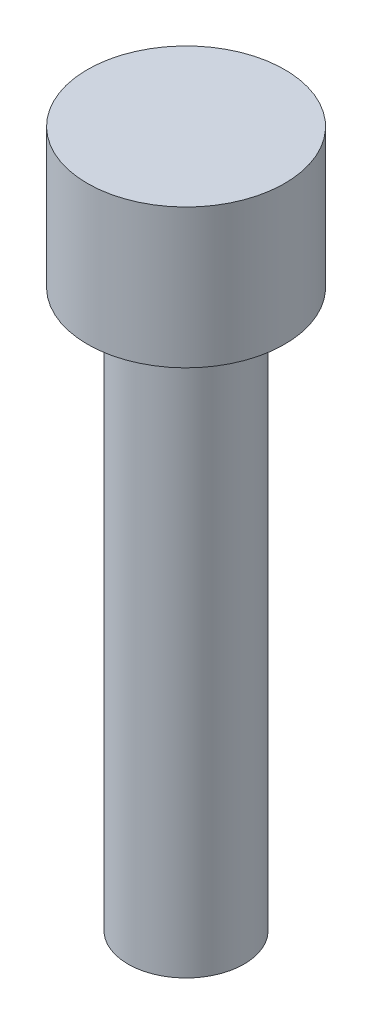
from build123d import *

# Parameters (mm, degrees)
SKETCH1_R           = 2.5
BOSS_EXTRUDE1_DEPTH = 24
SKETCH2_R           = 4.25
BOSS_EXTRUDE2_DEPTH = 6


with BuildPart() as part:
    # Sketch1 → Boss-Extrude1 (new body)
    with BuildSketch(Plane(origin=(0, 0, 0), x_dir=(1, 0, 0), z_dir=(0, 1, 0))):
        Circle(SKETCH1_R)
    extrude(amount=BOSS_EXTRUDE1_DEPTH)

    # Sketch2 → Boss-Extrude2 (add)
    with BuildSketch(Plane(origin=(0, 24, 0), x_dir=(1, 0, 0), z_dir=(0, 1, 0))):
        Circle(SKETCH2_R)
    extrude(amount=BOSS_EXTRUDE2_DEPTH)


solid = part.part
